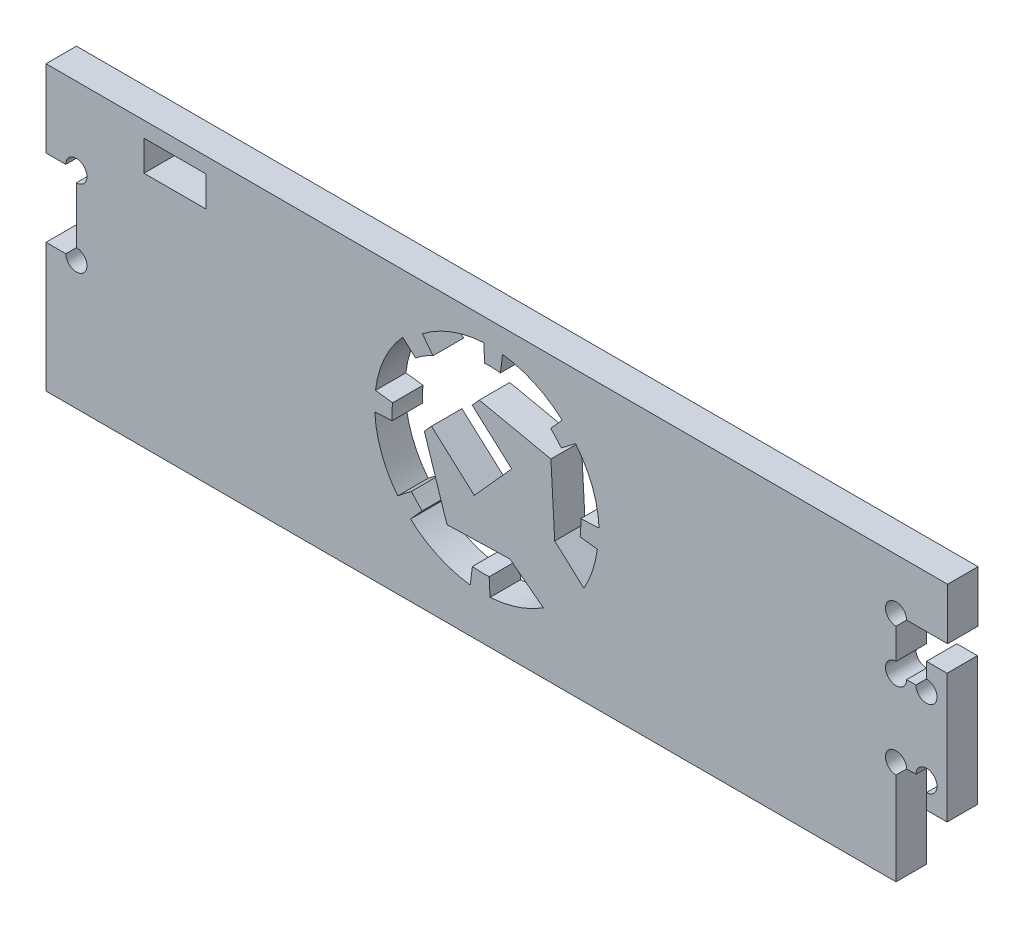
from build123d import *

# Parameters (mm, degrees)
SKETCH1_W           = 164.9
SKETCH1_H           = 55
BOSS_EXTRUDE1_DEPTH = 5.9
SKETCH2_W           = 5.9
SKETCH2_H           = 15
CUT_EXTRUDE1_DEPTH  = 6.9
BOSS_EXTRUDE2_DEPTH = 5.9
CUT_EXTRUDE2_DEPTH  = 10
SKETCH5_W           = 10
SKETCH5_H           = 10
BOSS_EXTRUDE3_DEPTH = 5.9
CUT_EXTRUDE3_REACH  = 7.9
SKETCH6_R           = 2.05
CUT_EXTRUDE4_REACH  = 7.9
SKETCH7_W           = 12
SKETCH7_H           = 5.9


with BuildPart() as part:
    # Sketch1 → Boss-Extrude1 (new body)
    with BuildSketch(Plane.XY):
        Rectangle(SKETCH1_W, SKETCH1_H)
    extrude(amount=BOSS_EXTRUDE1_DEPTH)

    # Sketch2 → Cut-Extrude1 (cut, through all)
    with BuildSketch(Plane.XY.offset(5.9)):
        with Locations((-79.5, 5)):
            Rectangle(SKETCH2_W, SKETCH2_H)
    extrude(amount=-CUT_EXTRUDE1_DEPTH, mode=Mode.SUBTRACT)

    # Sketch3 → Boss-Extrude2 (add)
    with BuildSketch(Plane.XY.offset(5.9)):
        Polygon((82.45, -7.5), (88.35, -7.5), (88.35, -12.5), (92.35, -12.5), (92.35, 12.5), (88.35, 12.5), (88.35, 7.5), (82.45, 7.5), align=None)
    extrude(amount=-BOSS_EXTRUDE2_DEPTH)

    # Sketch4 → Cut-Extrude2 (cut)
    with BuildSketch(Plane.XY.offset(5.9)):
        with BuildLine():
            Line((3.51583171, -15.706229716), (3.692822505, -19.080784973))
            ThreePointArc((3.692822505, -19.080784973), (9.080825588, -18.035079597), (14.033003188, -15.668644733))
            Line((14.033003188, -15.668644733), (7.525249631, -10.707966449))
            Line((7.525249631, -10.707966449), (-4.667323255, -11.041732232))
            Line((-4.667323255, -11.041732232), (-9.056316648, 2.465721032))
            Line((-9.056316648, 2.465721032), (-7.672540361, 3.987452797))
            Line((-7.672540361, 3.987452797), (0.63828327, -3.480150804))
            Line((0.63828327, -3.480150804), (7.889093057, 4.589420993))
            Line((7.889093057, 4.589420993), (0.219729645, 11.480963368))
            Line((0.219729645, 11.480963368), (1.603052795, 13.017301391))
            Line((1.603052795, 13.017301391), (15.495445969, 10.065059871))
            Line((15.495445969, 10.065059871), (16.237659976, -3.337384453))
            Line((16.237659976, -3.337384453), (21.895941701, -8.451220184))
            ThreePointArc((21.895941701, -8.451220184), (23.579573726, -4.648525456), (24.507536721, -0.594639829))
            Line((24.507536721, -0.594639829), (21.171770806, -0.180639971))
            ThreePointArc((21.171770806, -0.180639971), (21.286498935, 1.378538101), (21.285888417, 2.941931343))
            Line((21.285888417, 2.941931343), (24.837258291, 3.128195824))
            ThreePointArc((24.837258291, 3.128195824), (23.536690781, 9.458573353), (20.269548114, 15.034497878))
            Line((20.269548114, 15.034497878), (17.535016414, 12.941488009))
            ThreePointArc((17.535016414, 12.941488009), (16.508769514, 14.081533134), (15.445096221, 15.186741129))
            Line((15.445096221, 15.186741129), (17.692052457, 17.680150482))
            ThreePointArc((17.692052457, 17.680150482), (12.304554027, 21.210935864), (6.104308905, 22.956944215))
            Line((6.104308905, 22.956944215), (5.70284553, 19.6211861))
            ThreePointArc((5.70284553, 19.6211861), (4.176993745, 19.749298528), (2.645876068, 19.73154678))
            Line((2.645876068, 19.73154678), (2.474568352, 23.105152619))
            ThreePointArc((2.474568352, 23.105152619), (-3.819532601, 21.764454936), (-9.443176471, 18.635907879))
            Line((-9.443176471, 18.635907879), (-7.36611055, 15.97938168))
            ThreePointArc((-7.36611055, 15.97938168), (-9.138032671, 15.057329352), (-10.764172697, 13.897347837))
            Line((-10.764172697, 13.897347837), (-13.255215364, 16.14691078))
            ThreePointArc((-13.255215364, 16.14691078), (-16.804652941, 10.7695067), (-18.541993583, 4.564941506))
            Line((-18.541993583, 4.564941506), (-15.203305308, 4.160483172))
            ThreePointArc((-15.203305308, 4.160483172), (-15.337848427, 2.624728095), (-15.310082988, 1.083340867))
            Line((-15.310082988, 1.083340867), (-18.663730537, 0.907446652))
            ThreePointArc((-18.663730537, 0.907446652), (-17.372056658, -5.384049821), (-14.221680713, -10.981056224))
            Line((-14.221680713, -10.981056224), (-11.574159014, -8.917273625))
            ThreePointArc((-11.574159014, -8.917273625), (-10.549530454, -10.048759249), (-9.495391581, -11.15280392))
            Line((-9.495391581, -11.15280392), (-11.74257315, -13.641863724))
            ThreePointArc((-11.74257315, -13.641863724), (-6.357210629, -17.182483384), (-0.156549988, -18.940301546))
            Line((-0.156549988, -18.940301546), (0.271448667, -15.602569205))
            ThreePointArc((0.271448667, -15.602569205), (1.891578011, -15.718941802), (3.51583171, -15.706229716))
        make_face()
    extrude(amount=-CUT_EXTRUDE2_DEPTH, mode=Mode.SUBTRACT)

    # Sketch5 → Boss-Extrude3 (add)
    with BuildSketch(Plane(origin=(0, 0, 0), x_dir=(-1, 0, 0), z_dir=(0, 0, -1))):
        with Locations((-87.45, 22.5)):
            Rectangle(SKETCH5_W, SKETCH5_H)
    extrude(amount=-BOSS_EXTRUDE3_DEPTH)

    # Sketch6 → Cut-Extrude3 (cut, up to next)
    with BuildSketch(Plane(origin=(0, 0, 0), x_dir=(-1, 0, 0), z_dir=(0, 0, -1)), mode=Mode.PRIVATE) as cut_extrude3_sk1:
        with Locations((-82.45, -7.5)):
            Circle(SKETCH6_R)
    cut_extrude3_tool1 = extrude(cut_extrude3_sk1.sketch, amount=-CUT_EXTRUDE3_REACH, mode=Mode.PRIVATE) & part.part
    add(cut_extrude3_tool1.solids().sort_by_distance((82.45, -7.5, 0))[0], mode=Mode.SUBTRACT)
    # Sketch6 → Cut-Extrude3 (cut, up to next)
    with BuildSketch(Plane(origin=(0, 0, 0), x_dir=(-1, 0, 0), z_dir=(0, 0, -1)), mode=Mode.PRIVATE) as cut_extrude3_sk2:
        with Locations((-88.35, -7.5)):
            Circle(SKETCH6_R)
    cut_extrude3_tool2 = extrude(cut_extrude3_sk2.sketch, amount=-CUT_EXTRUDE3_REACH, mode=Mode.PRIVATE) & part.part
    add(cut_extrude3_tool2.solids().sort_by_distance((88.35, -7.5, 0))[0], mode=Mode.SUBTRACT)
    # Sketch6 → Cut-Extrude3 (cut, up to next)
    with BuildSketch(Plane(origin=(0, 0, 0), x_dir=(-1, 0, 0), z_dir=(0, 0, -1)), mode=Mode.PRIVATE) as cut_extrude3_sk3:
        with Locations((-88.35, 7.5)):
            Circle(SKETCH6_R)
    cut_extrude3_tool3 = extrude(cut_extrude3_sk3.sketch, amount=-CUT_EXTRUDE3_REACH, mode=Mode.PRIVATE) & part.part
    add(cut_extrude3_tool3.solids().sort_by_distance((88.35, 7.5, 0))[0], mode=Mode.SUBTRACT)
    # Sketch6 → Cut-Extrude3 (cut, up to next)
    with BuildSketch(Plane(origin=(0, 0, 0), x_dir=(-1, 0, 0), z_dir=(0, 0, -1)), mode=Mode.PRIVATE) as cut_extrude3_sk4:
        with Locations((-82.45, 7.5)):
            Circle(SKETCH6_R)
    cut_extrude3_tool4 = extrude(cut_extrude3_sk4.sketch, amount=-CUT_EXTRUDE3_REACH, mode=Mode.PRIVATE) & part.part
    add(cut_extrude3_tool4.solids().sort_by_distance((82.45, 7.5, 0))[0], mode=Mode.SUBTRACT)
    # Sketch6 → Cut-Extrude3 (cut, up to next)
    with BuildSketch(Plane(origin=(0, 0, 0), x_dir=(-1, 0, 0), z_dir=(0, 0, -1)), mode=Mode.PRIVATE) as cut_extrude3_sk5:
        with Locations((-82.45, 17.5)):
            Circle(SKETCH6_R)
    cut_extrude3_tool5 = extrude(cut_extrude3_sk5.sketch, amount=-CUT_EXTRUDE3_REACH, mode=Mode.PRIVATE) & part.part
    add(cut_extrude3_tool5.solids().sort_by_distance((82.45, 17.5, 0))[0], mode=Mode.SUBTRACT)
    # Sketch6 → Cut-Extrude3 (cut, up to next)
    with BuildSketch(Plane(origin=(0, 0, 0), x_dir=(-1, 0, 0), z_dir=(0, 0, -1)), mode=Mode.PRIVATE) as cut_extrude3_sk6:
        with Locations((76.55, 12.5)):
            Circle(SKETCH6_R)
    cut_extrude3_tool6 = extrude(cut_extrude3_sk6.sketch, amount=-CUT_EXTRUDE3_REACH, mode=Mode.PRIVATE) & part.part
    add(cut_extrude3_tool6.solids().sort_by_distance((-76.55, 12.5, 0))[0], mode=Mode.SUBTRACT)
    # Sketch6 → Cut-Extrude3 (cut, up to next)
    with BuildSketch(Plane(origin=(0, 0, 0), x_dir=(-1, 0, 0), z_dir=(0, 0, -1)), mode=Mode.PRIVATE) as cut_extrude3_sk7:
        with Locations((76.55, -2.5)):
            Circle(SKETCH6_R)
    cut_extrude3_tool7 = extrude(cut_extrude3_sk7.sketch, amount=-CUT_EXTRUDE3_REACH, mode=Mode.PRIVATE) & part.part
    add(cut_extrude3_tool7.solids().sort_by_distance((-76.55, -2.5, 0))[0], mode=Mode.SUBTRACT)

    # Sketch7 → Cut-Extrude4 (cut, up to next)
    with BuildSketch(Plane(origin=(0, 0, 0), x_dir=(-1, 0, 0), z_dir=(0, 0, -1)), mode=Mode.PRIVATE) as cut_extrude4_sk1:
        with Locations((57.45, 21.55)):
            Rectangle(SKETCH7_W, SKETCH7_H)
    cut_extrude4_tool1 = extrude(cut_extrude4_sk1.sketch, amount=-CUT_EXTRUDE4_REACH, mode=Mode.PRIVATE) & part.part
    add(cut_extrude4_tool1.solids().sort_by_distance((-57.45, 21.55, 0))[0], mode=Mode.SUBTRACT)


solid = part.part
